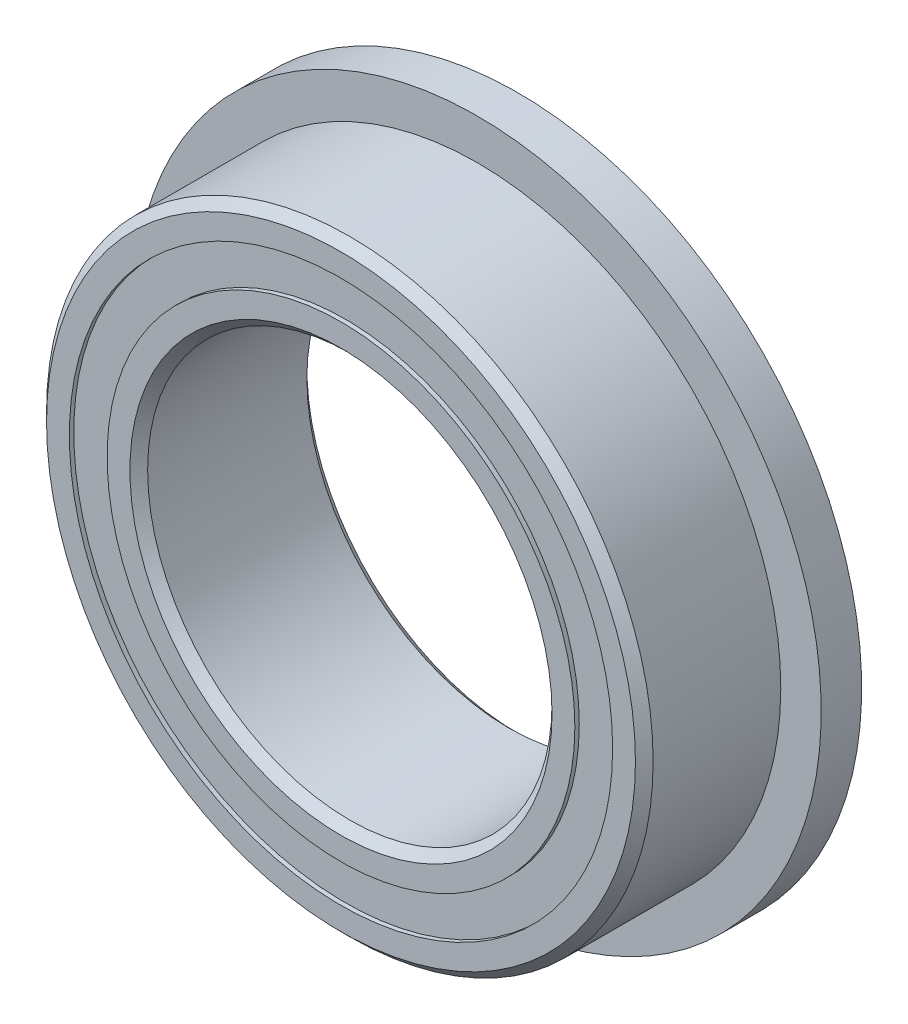
from build123d import *

# Parameters (mm, degrees)
CIRPATTERN1_COUNT = 12
SKETCH5_W         = 0.79963562
SKETCH5_H         = 0.747252748
SKETCH6_W         = 0.8
SKETCH6_H         = 1.426373626


with BuildPart() as part:
    # Sketch1 → Revolve1 (revolve)
    with BuildSketch(Plane(origin=(0, 0, 0), x_dir=(0, 0, -1), z_dir=(1, 0, 0))):
        with BuildLine():
            Line((1.575, 6), (-1.575, 6))
            Line((-1.575, 6), (-1.75, 5.825))
            Line((-1.75, 5.825), (-1.75, 5.373626374))
            Line((-1.75, 5.373626374), (-0.777777778, 5.373626374))
            ThreePointArc((-0.777777778, 5.373626374), (0, 5.86286438), (0.777777778, 5.373626374))
            Line((0.777777778, 5.373626374), (1.75, 5.373626374))
            Line((1.75, 5.373626374), (1.75, 5.825))
            Line((1.75, 5.825), (1.575, 6))
        make_face()
    revolve(axis=Axis((0, 0, 1.75), (0, 0, -1)))

    # Sketch6 → Revolve6 (revolve)
    with BuildSketch(Plane(origin=(0, 0, 0), x_dir=(0, 0, -1), z_dir=(1, 0, 0))):
        with Locations((1.35, 6.086813187)):
            Rectangle(SKETCH6_W, SKETCH6_H)
    revolve(axis=Axis((0, 0, -1.75), (0, 0, 1)))


with BuildPart() as body_2:
    # Sketch3 → Revolve3 (revolve)
    with BuildSketch(Plane(origin=(0, 0, 0), x_dir=(0, 0, -1), z_dir=(1, 0, 0))):
        with BuildLine():
            Line((-1.75, 4.626373626), (-0.777777778, 4.626373626))
            ThreePointArc((-0.777777778, 4.626373626), (0, 4.13713562), (0.777777778, 4.626373626))
            Line((0.777777778, 4.626373626), (1.75, 4.626373626))
            Line((1.75, 4.626373626), (1.75, 4.175))
            Line((1.75, 4.175), (1.575, 4))
            Line((1.575, 4), (-1.575, 4))
            Line((-1.575, 4), (-1.75, 4.175))
            Line((-1.75, 4.175), (-1.75, 4.626373626))
        make_face()
    revolve(axis=Axis((0, 0, 1.75), (0, 0, -1)))


with BuildPart() as body_3:
    # Sketch4 → Revolve4 (revolve)
    with BuildSketch(Plane(origin=(0, 0, 0), x_dir=(0, 0, -1), z_dir=(1, 0, 0))):
        with BuildLine():
            Line((-0.86286438, 5), (0.86286438, 5))
            ThreePointArc((0.86286438, 5), (0, 5.86286438), (-0.86286438, 5))
        make_face()
    revolve(axis=Axis((0, 5, 0.86286438), (0, 0, -1)))


with BuildPart() as cirpattern1_1:
    # CirPattern1: pattern copy
    add(body_3.part.rotate(Axis((0, 0, -1.75), (0, 0, 1)), 1 * 360 / CIRPATTERN1_COUNT))


with BuildPart() as cirpattern1_2:
    # CirPattern1: pattern copy
    add(body_3.part.rotate(Axis((0, 0, -1.75), (0, 0, 1)), 2 * 360 / CIRPATTERN1_COUNT))


with BuildPart() as cirpattern1_3:
    # CirPattern1: pattern copy
    add(body_3.part.rotate(Axis((0, 0, -1.75), (0, 0, 1)), 3 * 360 / CIRPATTERN1_COUNT))


with BuildPart() as cirpattern1_4:
    # CirPattern1: pattern copy
    add(body_3.part.rotate(Axis((0, 0, -1.75), (0, 0, 1)), 4 * 360 / CIRPATTERN1_COUNT))


with BuildPart() as cirpattern1_5:
    # CirPattern1: pattern copy
    add(body_3.part.rotate(Axis((0, 0, -1.75), (0, 0, 1)), 5 * 360 / CIRPATTERN1_COUNT))


with BuildPart() as cirpattern1_6:
    # CirPattern1: pattern copy
    add(body_3.part.rotate(Axis((0, 0, -1.75), (0, 0, 1)), 6 * 360 / CIRPATTERN1_COUNT))


with BuildPart() as cirpattern1_7:
    # CirPattern1: pattern copy
    add(body_3.part.rotate(Axis((0, 0, -1.75), (0, 0, 1)), 7 * 360 / CIRPATTERN1_COUNT))


with BuildPart() as cirpattern1_8:
    # CirPattern1: pattern copy
    add(body_3.part.rotate(Axis((0, 0, -1.75), (0, 0, 1)), 8 * 360 / CIRPATTERN1_COUNT))


with BuildPart() as cirpattern1_9:
    # CirPattern1: pattern copy
    add(body_3.part.rotate(Axis((0, 0, -1.75), (0, 0, 1)), 9 * 360 / CIRPATTERN1_COUNT))


with BuildPart() as cirpattern1_10:
    # CirPattern1: pattern copy
    add(body_3.part.rotate(Axis((0, 0, -1.75), (0, 0, 1)), 10 * 360 / CIRPATTERN1_COUNT))


with BuildPart() as cirpattern1_11:
    # CirPattern1: pattern copy
    add(body_3.part.rotate(Axis((0, 0, -1.75), (0, 0, 1)), 11 * 360 / CIRPATTERN1_COUNT))


with BuildPart() as body_15:
    # Sketch5 → Revolve5 (revolve)
    with BuildSketch(Plane(origin=(0, 0, 0), x_dir=(0, 0, -1), z_dir=(1, 0, 0))):
        with Locations((-1.26268219, 5)):
            Rectangle(SKETCH5_W, SKETCH5_H)
        with Locations((1.26268219, 5)):
            Rectangle(SKETCH5_W, SKETCH5_H)
    revolve(axis=Axis((0, 0, 1.75), (0, 0, -1)))


solid = Compound([part.part, body_2.part, body_3.part, cirpattern1_1.part, cirpattern1_2.part, cirpattern1_3.part, cirpattern1_4.part, cirpattern1_5.part, cirpattern1_6.part, cirpattern1_7.part, cirpattern1_8.part, cirpattern1_9.part, cirpattern1_10.part, cirpattern1_11.part, body_15.part])
